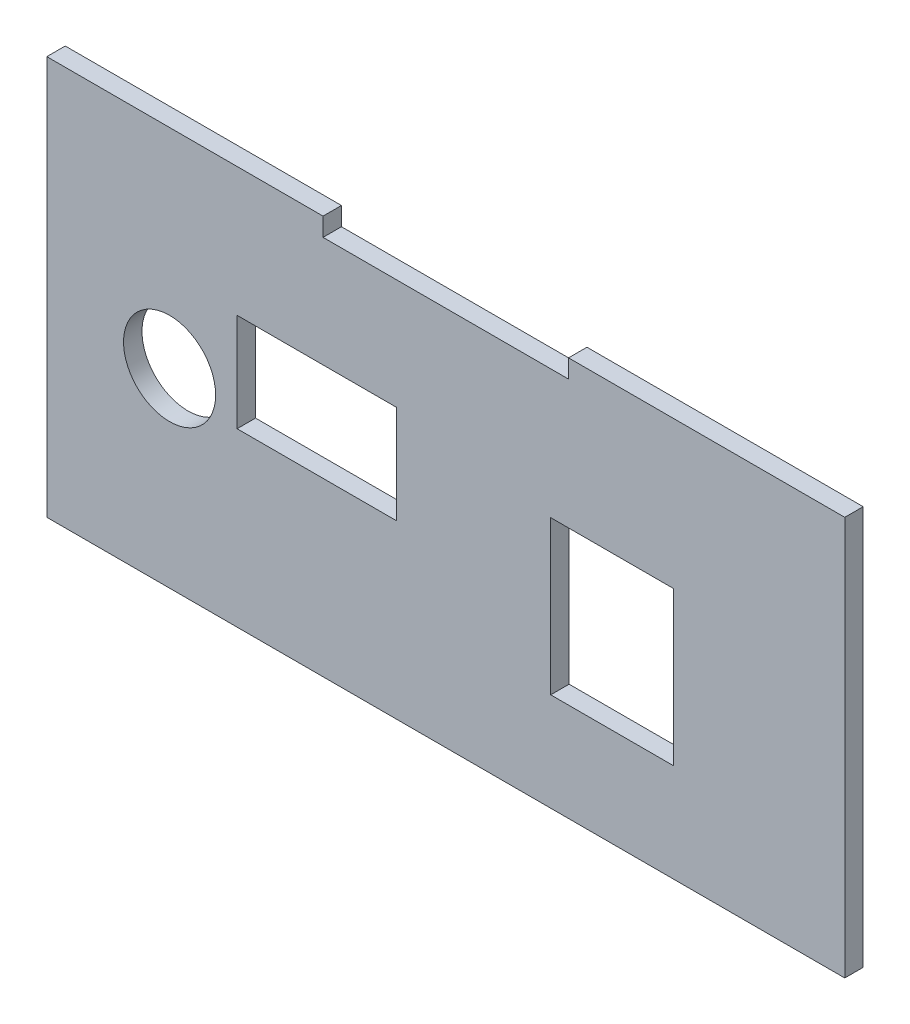
from build123d import *

# Parameters (mm, degrees)
ESBO_O2_R                = 7.5
ESBO_O2_W                = 20
ESBO_O2_H                = 25
ESBO_O2_W_2              = 26
ESBO_O2_H_2              = 16
RESSALTO_EXTRUS_O1_DEPTH = 3


with BuildPart() as part:
    # Esboço2 → Ressalto-extrusão1 (new body)
    with BuildSketch(Plane.XY):
        Polygon((-50.047132184, 49.044084736), (-95.047132184, 49.044084736), (-95.047132184, -15.955915264), (34.952867816, -15.955915264), (34.952867816, 49.044084736), (-10.047132184, 49.044084736), (-10.047132184, 46.044084736), (-50.047132184, 46.044084736), align=None)
        with Locations((-75.047132184, 15.044084736)):
            Circle(ESBO_O2_R, mode=Mode.SUBTRACT)
        with Locations((-2.954931, 12.544084736)):
            Rectangle(ESBO_O2_W, ESBO_O2_H, mode=Mode.SUBTRACT)
        with Locations((-51.047132184, 20.044084736)):
            Rectangle(ESBO_O2_W_2, ESBO_O2_H_2, mode=Mode.SUBTRACT)
    extrude(amount=-RESSALTO_EXTRUS_O1_DEPTH)


solid = part.part
